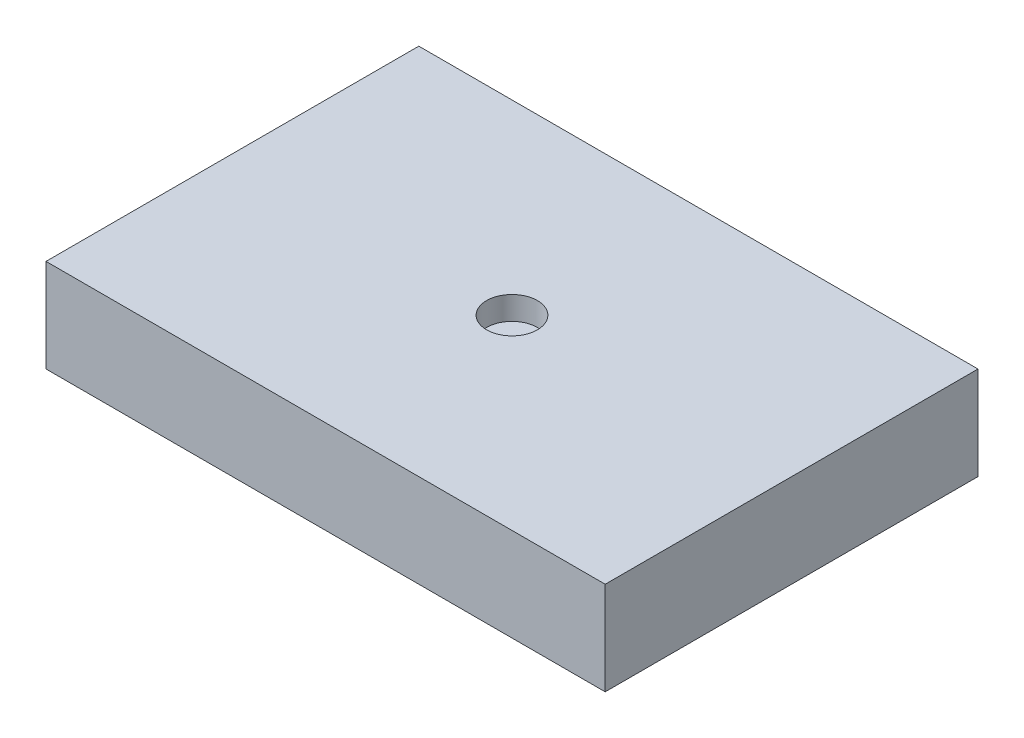
from build123d import *

# Parameters (mm, degrees)
SKETCH1_W           = 30.48
SKETCH1_H           = 20.32
BOSS_EXTRUDE1_DEPTH = 5.08
SKETCH2_R           = 1.383874396
CUT_EXTRUDE1_DEPTH  = 1.27


with BuildPart() as part:
    # Sketch1 → Boss-Extrude1 (new body)
    with BuildSketch(Plane(origin=(0, 0, 0), x_dir=(1, 0, 0), z_dir=(0, 1, 0))):
        Rectangle(SKETCH1_W, SKETCH1_H)
    extrude(amount=BOSS_EXTRUDE1_DEPTH)

    # Sketch2 → Cut-Extrude1 (cut)
    with BuildSketch(Plane(origin=(0, 5.08, 0), x_dir=(1, 0, 0), z_dir=(0, 1, 0))):
        Circle(SKETCH2_R)
    extrude(amount=-CUT_EXTRUDE1_DEPTH, mode=Mode.SUBTRACT)


solid = part.part
